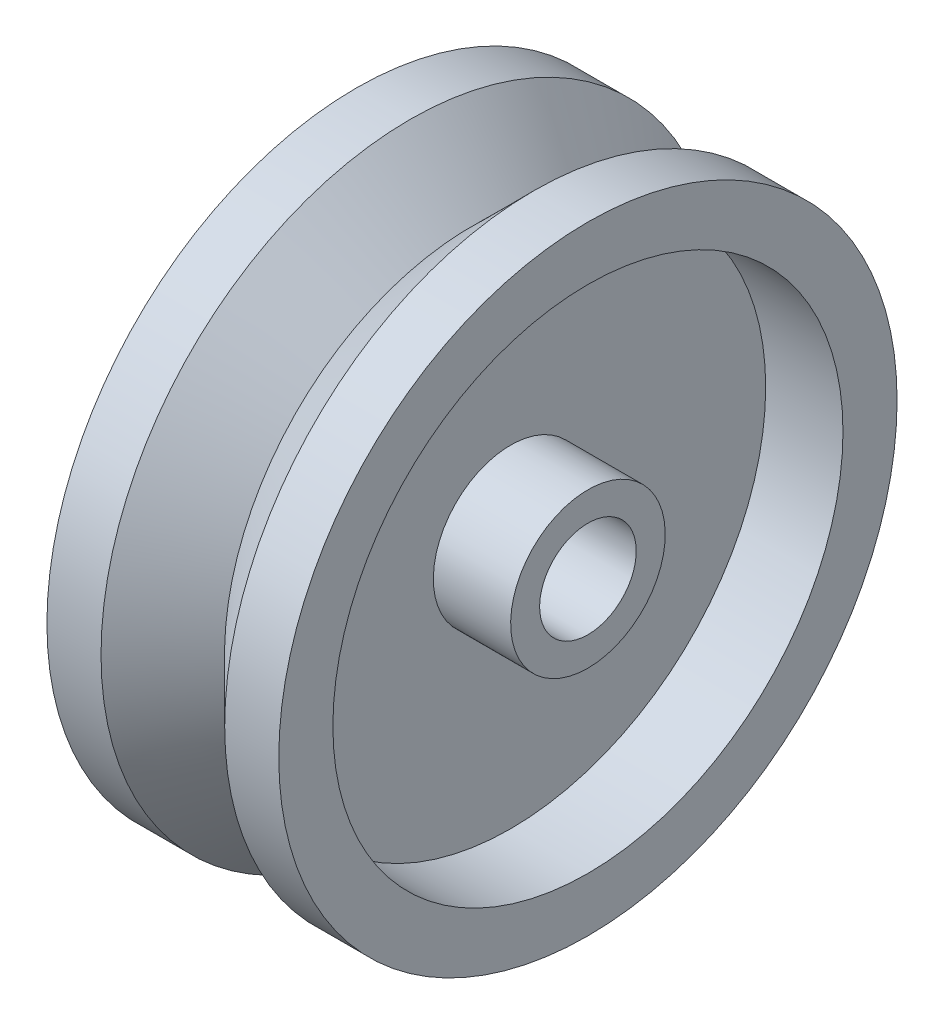
from build123d import *

# Parameters (mm, degrees)
REVOLVE1_ANGLE = 360


with BuildPart() as part:
    # Sketch1 → Revolve1 (revolve, symmetric)
    with BuildSketch(Plane.XY) as revolve1_sk:
        Polygon((7.5, 3.125), (-7.5, 3.125), (-7.5, 5), (-2.5, 5), (-2.5, 16.5), (-7.5, 16.5), (-7.5, 20), (-4, 20), (-0.010995646, 16.000015113), (4, 20), (7.5, 20), (7.5, 16.5), (2.5, 16.5), (2.5, 5), (7.5, 5), align=None)
    revolve(axis=Axis((-7.5, 0, 0), (1, 0, 0)), revolution_arc=REVOLVE1_ANGLE / 2)
    revolve(revolve1_sk.sketch, axis=Axis((-7.5, 0, 0), (-1, 0, 0)), revolution_arc=REVOLVE1_ANGLE / 2)


solid = part.part
